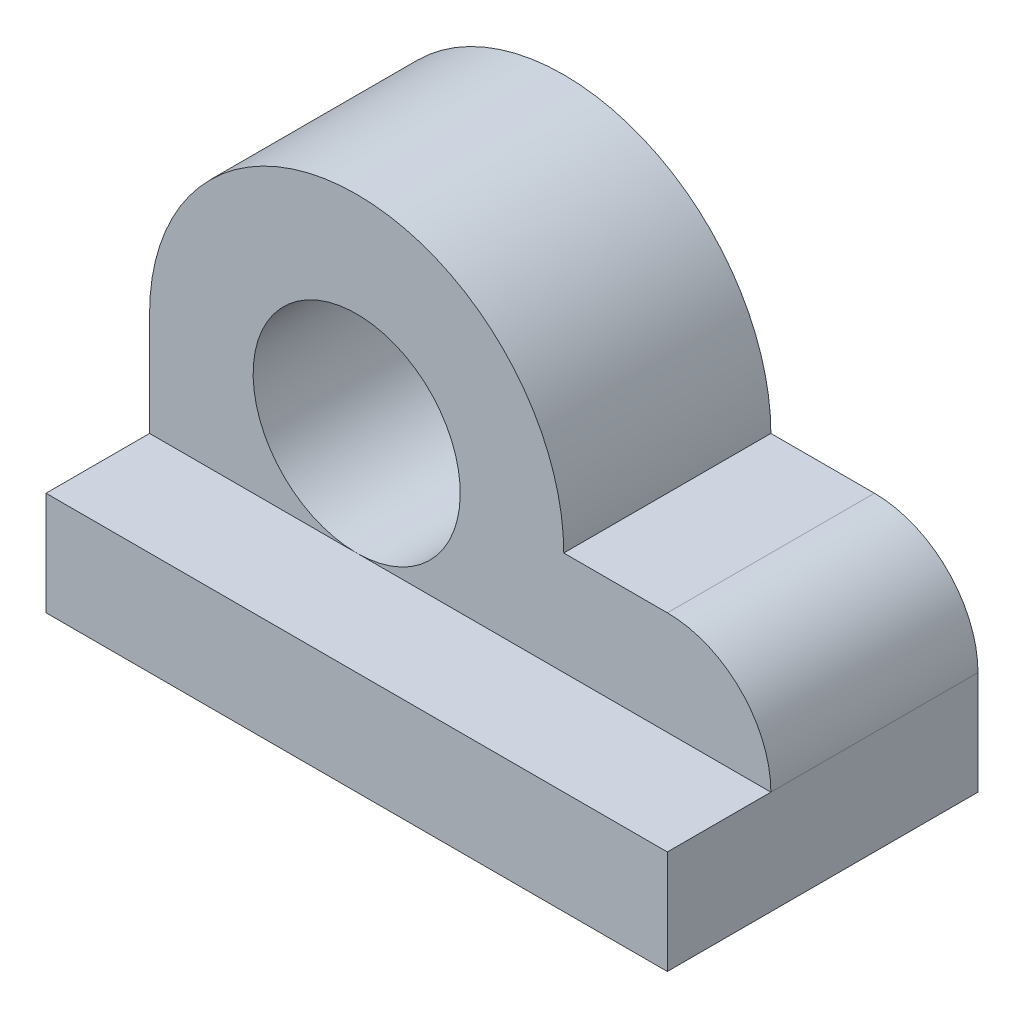
from build123d import *

# Parameters (mm, degrees)
SKETCH_1_R      = 5
EXTRUDE_1_DEPTH = 10
EXTRUDE_2_DEPTH = 15


with BuildPart() as part:
    # 草圖1 → 填料-伸長1 (new body)
    with BuildSketch(Plane.XY):
        with BuildLine():
            ThreePointArc((10, 0), (0, 10), (-10, 0))
            Line((-10, 0), (-10, -10))
            Line((-10, -10), (20, -10))
            Line((20, -10), (20, -5))
            ThreePointArc((20, -5), (18.535533906, -1.464466094), (15, 0))
            Line((15, 0), (10, 0))
        make_face()
        Circle(SKETCH_1_R, mode=Mode.SUBTRACT)
    extrude(amount=EXTRUDE_1_DEPTH)

    # 草圖1<3> → 填料-伸長2 (add)
    with BuildSketch(Plane.XY):
        Polygon((0, -5), (-10, -5), (-10, -10), (20, -10), (20, -5), align=None)
    extrude(amount=EXTRUDE_2_DEPTH)


solid = part.part
